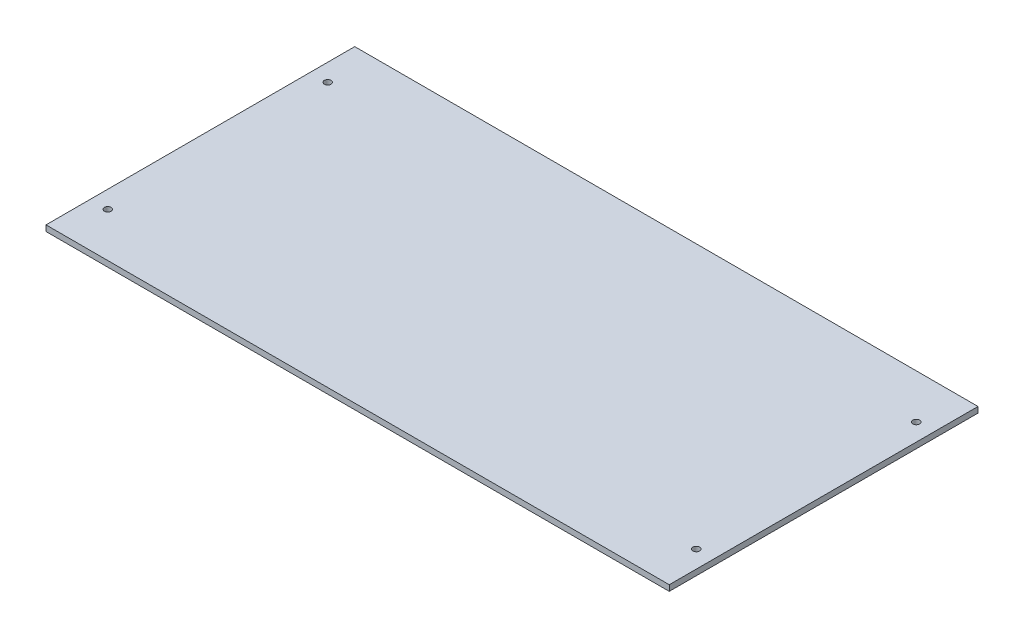
from build123d import *

# Parameters (mm, degrees)
SKETCH1_W           = 323
SKETCH1_H           = 160
BOSS_EXTRUDE1_DEPTH = 3
SKETCH2_R           = 1.75
CUT_EXTRUDE1_DEPTH  = 4


with BuildPart() as part:
    # Sketch1 → Boss-Extrude1 (new body)
    with BuildSketch(Plane(origin=(0, 0, 0), x_dir=(1, 0, 0), z_dir=(0, 1, 0))):
        Rectangle(SKETCH1_W, SKETCH1_H)
    extrude(amount=BOSS_EXTRUDE1_DEPTH)

    # Sketch2 → Cut-Extrude1 (cut, through all)
    with BuildSketch(Plane.XZ):
        with Locations(Location((-152.5, -57, 0), (0, 0, 270))):  # turned: the seam where the file's is
            Circle(SKETCH2_R)
        with Locations(Location((152.5, -57, 0), (0, 0, 270))):  # turned: the seam where the file's is
            Circle(SKETCH2_R)
        with Locations(Location((152.5, 57, 0), (0, 0, 90))):  # turned: the seam where the file's is
            Circle(SKETCH2_R)
        with Locations(Location((-152.5, 57, 0), (0, 0, 90))):  # turned: the seam where the file's is
            Circle(SKETCH2_R)
    extrude(amount=-CUT_EXTRUDE1_DEPTH, mode=Mode.SUBTRACT)


solid = part.part
